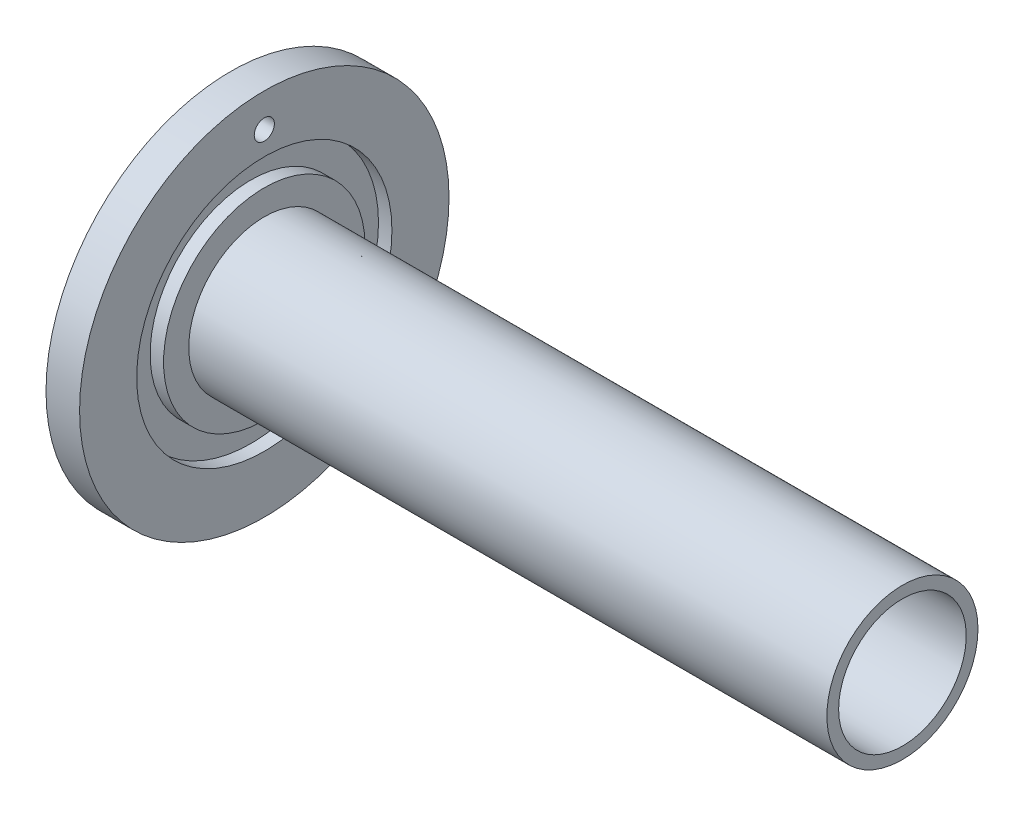
from build123d import *

# Parameters (mm, degrees)
SKETCH2_R               = 55
BOSS_EXTRUDE1_DEPTH     = 10
SKETCH3_R               = 22.5
BOSS_EXTRUDE2_DEPTH     = 190
SKETCH4_R               = 19
CUT_EXTRUDE1_DEPTH      = 1
CUT_EXTRUDE1_DEPTH_BACK = 201
SKETCH14_R              = 37.5
SKETCH14_R_2            = 30.5
CUT_EXTRUDE5_DEPTH      = 1
SKETCH15_R              = 38
SKETCH15_R_2            = 30
CUT_EXTRUDE6_DEPTH      = 4
SKETCH16_R              = 2.5
CUT_EXTRUDE7_DEPTH      = 4
SKETCH17_R              = 5
CUT_EXTRUDE8_DEPTH      = 2
SKETCH20_R              = 3
CUT_EXTRUDE9_DEPTH      = 10
SKETCH21_R              = 3
CUT_EXTRUDE10_DEPTH     = 10


with BuildPart() as part:
    # Sketch2 → Boss-Extrude1 (new body)
    with BuildSketch(Plane(origin=(0, 0, 0), x_dir=(0, 0, -1), z_dir=(1, 0, 0))):
        Circle(SKETCH2_R)
    extrude(amount=BOSS_EXTRUDE1_DEPTH)

    # Sketch3 → Boss-Extrude2 (add)
    with BuildSketch(Plane(origin=(10, 0, 0), x_dir=(0, 0, -1), z_dir=(1, 0, 0))):
        Circle(SKETCH3_R)
    extrude(amount=BOSS_EXTRUDE2_DEPTH)

    # Sketch4 → Cut-Extrude1 (cut, two sides)
    with BuildSketch(Plane.ZY) as cut_extrude1_sk:
        Circle(SKETCH4_R)
    extrude(amount=CUT_EXTRUDE1_DEPTH, mode=Mode.SUBTRACT)
    extrude(cut_extrude1_sk.sketch, amount=-CUT_EXTRUDE1_DEPTH_BACK, mode=Mode.SUBTRACT)

    # Sketch14 → Cut-Extrude5 (cut)
    with BuildSketch(Plane.ZY):
        Circle(SKETCH14_R)
        Circle(SKETCH14_R_2, mode=Mode.SUBTRACT)
    extrude(amount=-CUT_EXTRUDE5_DEPTH, mode=Mode.SUBTRACT)

    # Sketch15 → Cut-Extrude6 (cut)
    with BuildSketch(Plane(origin=(10, 0, 0), x_dir=(0, 0, -1), z_dir=(1, 0, 0))):
        Circle(SKETCH15_R)
        Circle(SKETCH15_R_2, mode=Mode.SUBTRACT)
    extrude(amount=-CUT_EXTRUDE6_DEPTH, mode=Mode.SUBTRACT)

    # Sketch16 → Cut-Extrude7 (cut)
    with BuildSketch(Plane.ZY):
        with Locations((0, 34)):
            Circle(SKETCH16_R)
        with Locations((0, -34)):
            Circle(SKETCH16_R)
    extrude(amount=-CUT_EXTRUDE7_DEPTH, mode=Mode.SUBTRACT)

    # Sketch17 → Cut-Extrude8 (cut)
    with BuildSketch(Plane.ZY):
        with Locations((0, -34)):
            Circle(SKETCH17_R)
        with Locations((0, 34)):
            Circle(SKETCH17_R)
    extrude(amount=-CUT_EXTRUDE8_DEPTH, mode=Mode.SUBTRACT)

    # Sketch20 → Cut-Extrude9 (cut)
    with BuildSketch(Plane.ZY):
        with Locations((-26, 0)):
            Circle(SKETCH20_R)
    extrude(amount=-CUT_EXTRUDE9_DEPTH, mode=Mode.SUBTRACT)

    # Sketch21 → Cut-Extrude10 (cut)
    with BuildSketch(Plane.ZY):
        with Locations((0, 45)):
            Circle(SKETCH21_R)
    extrude(amount=-CUT_EXTRUDE10_DEPTH, mode=Mode.SUBTRACT)


solid = part.part
